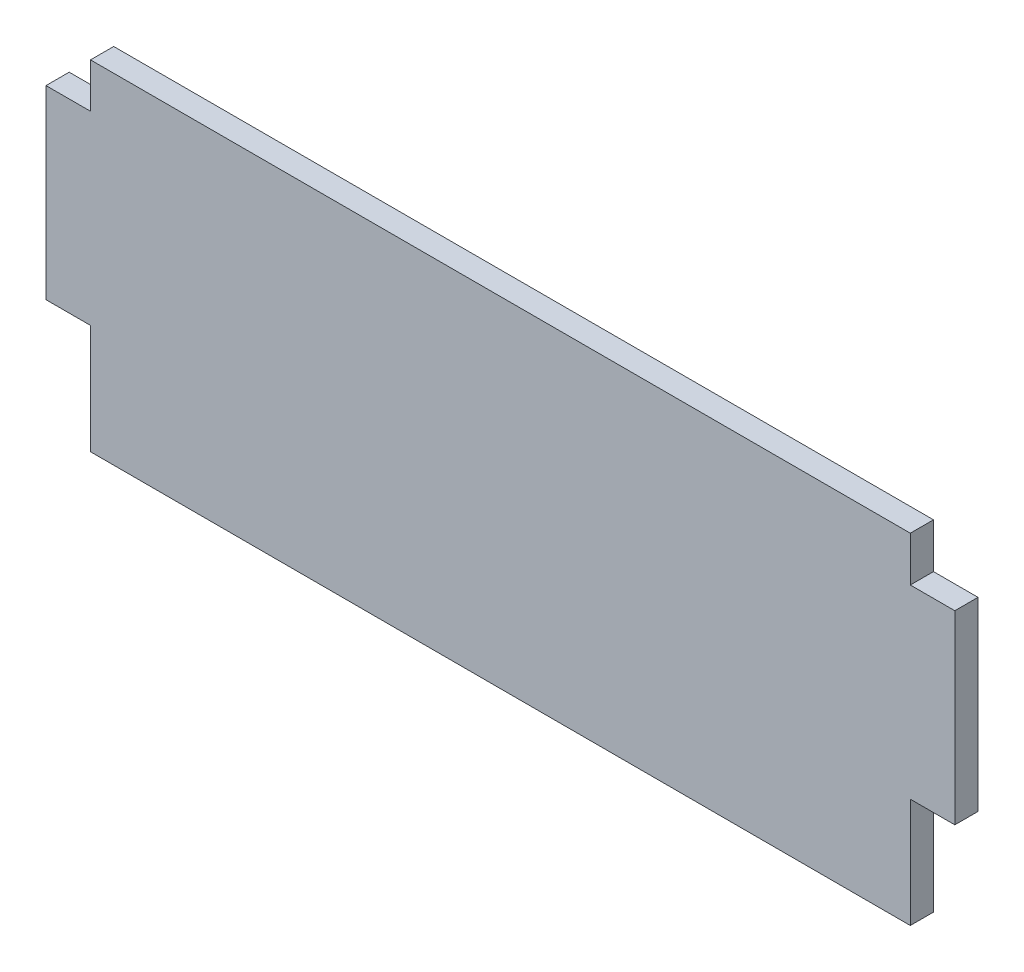
from build123d import *

# Parameters (mm, degrees)
BOSS_EXTRUDE1_DEPTH = 1.5875


with BuildPart() as part:
    # Sketch1 → Boss-Extrude1 (new body)
    with BuildSketch(Plane.XY):
        Polygon((0, 88.011001237), (-3.048, 88.011001237), (-3.048, 75.311002322), (0, 75.311002322), (0, 67.817998119), (56.134000346, 67.792591639), (56.134000346, 75.285595842), (59.182000346, 75.285595842), (59.182000346, 87.985594757), (56.134000346, 87.985594757), (56.134000421, 91.058996506), (0, 91.058996506), align=None)
    extrude(amount=BOSS_EXTRUDE1_DEPTH)


solid = part.part
